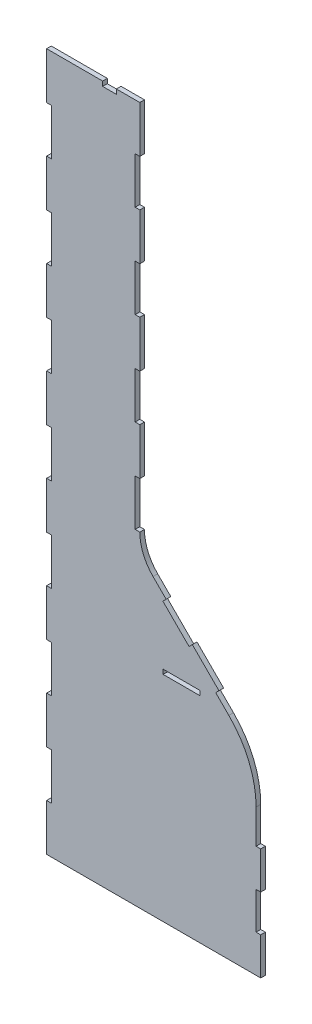
from build123d import *

# Parameters (mm, degrees)
ESQUISSE1_W             = 39.8
ESQUISSE1_H             = 4.9
BOSS_EXTRU_1_DEPTH      = 5
ENL_V_MAT_EXTRU_1_REACH = 7
BOSS_EXTRU_2_DEPTH      = 5


with BuildPart() as part:
    # Esquisse1 → Boss.-Extru.1 (new body)
    with BuildSketch(Plane.XY):
        Polygon((100.1, 330.041421356), (128.425692604, 301.715728753), (124.890158698, 298.180194847), (153.033008589, 270.037344955), (156.568542495, 273.572878861), (200.043297184, 230.098124172), (196.507763279, 226.562590266), (211.415404008, 211.654949536), (214.950937914, 215.190483442), (230.1, 200.041421356), (230.1, 159.9), (225.1, 159.9), (225.1, 120.1), (230.1, 120.1), (230.1, 79.9), (225.1, 79.9), (225.1, 40.1), (230.1, 40.1), (230.1, -0.1), (-0.1, -0.1), (-0.1, 50.1), (4.9, 50.1), (4.9, 99.9), (-0.1, 99.9), (-0.1, 150.1), (4.9, 150.1), (4.9, 199.9), (-0.1, 199.9), (-0.1, 250.1), (4.9, 250.1), (4.9, 299.9), (-0.1, 299.9), (-0.1, 350.1), (4.9, 350.1), (4.9, 399.9), (-0.1, 399.9), (-0.1, 450.1), (4.9, 450.1), (4.9, 499.9), (-0.1, 499.9), (-0.1, 550.1), (4.9, 550.1), (4.9, 599.9), (-0.1, 599.9), (-0.1, 650.1), (4.9, 650.1), (4.9, 699.9), (-0.1, 699.9), (-0.1, 750.1), (60.1, 750.1), (60.1, 745.1), (74.9, 745.1), (74.9, 750.1), (100.1, 750.1), (100.1, 699.9), (95.1, 699.9), (95.1, 650.1), (100.1, 650.1), (100.1, 599.9), (95.1, 599.9), (95.1, 550.1), (100.1, 550.1), (100.1, 499.9), (95.1, 499.9), (95.1, 450.1), (100.1, 450.1), (100.1, 399.9), (95.1, 399.9), (95.1, 350.1), (100.1, 350.1), align=None)
        with Locations((145, 232.55)):
            Rectangle(ESQUISSE1_W, ESQUISSE1_H, mode=Mode.SUBTRACT)
    extrude(amount=BOSS_EXTRU_1_DEPTH)

    # Esquisse3 → Enlèv. mat.-Extru.1 (cut, up to next)
    with BuildSketch(Plane.XY.offset(5), mode=Mode.PRIVATE) as enl_v_mat_extru_1_sk1:
        with BuildLine():
            Line((225.1, 156.548997307), (230.1, 156.548997307))
            Line((230.1, 156.548997307), (230.1, 200.041421356))
            Line((230.1, 200.041421356), (185.204076401, 244.937344955))
            Line((185.204076401, 244.937344955), (181.668542495, 241.401811049))
            Line((181.668542495, 241.401811049), (195.810678119, 227.259675426))
            ThreePointArc((195.810678119, 227.259675426), (217.487953251, 194.817340544), (225.1, 156.548997307))
        make_face()
    enl_v_mat_extru_1_tool1 = extrude(enl_v_mat_extru_1_sk1.sketch, amount=-ENL_V_MAT_EXTRU_1_REACH, mode=Mode.PRIVATE) & part.part
    add(enl_v_mat_extru_1_tool1.solids().sort_by_distance((215.811514, 201.214449, 5))[0], mode=Mode.SUBTRACT)

    # Esquisse4 → Boss.-Extru.2 (add)
    with BuildSketch(Plane.XY.offset(5)):
        with BuildLine():
            Line((100.1, 350.1), (100.1, 330.041421356))
            Line((100.1, 330.041421356), (114.28355698, 315.857864376))
            ThreePointArc((114.28355698, 315.857864376), (103.786186359, 331.56828974), (100.1, 350.1))
        make_face()
    extrude(amount=-BOSS_EXTRU_2_DEPTH)


solid = part.part
